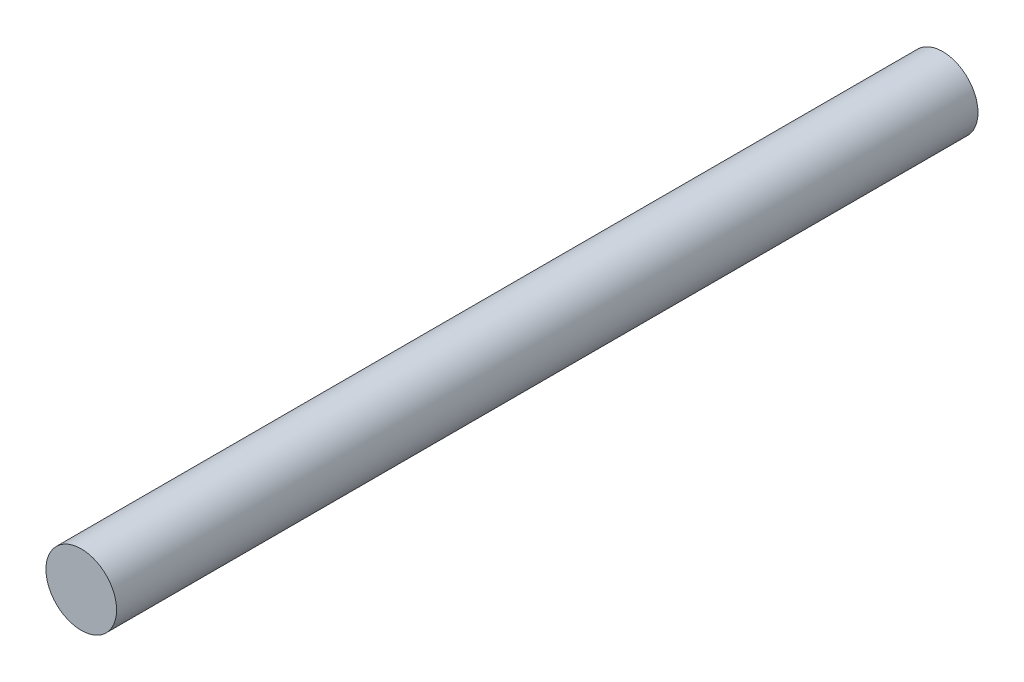
from build123d import *

# Parameters (mm, degrees)
SKETCH3_R                = 25
BOSS_EXTRUDE1_DEPTH      = 304.8
BOSS_EXTRUDE1_DEPTH_BACK = 304.8


with BuildPart() as part:
    # Sketch3 → Boss-Extrude1 (new body, two sides)
    with BuildSketch(Plane.XY) as boss_extrude1_sk:
        Circle(SKETCH3_R)
    extrude(amount=BOSS_EXTRUDE1_DEPTH)
    extrude(boss_extrude1_sk.sketch, amount=-BOSS_EXTRUDE1_DEPTH_BACK)


solid = part.part
